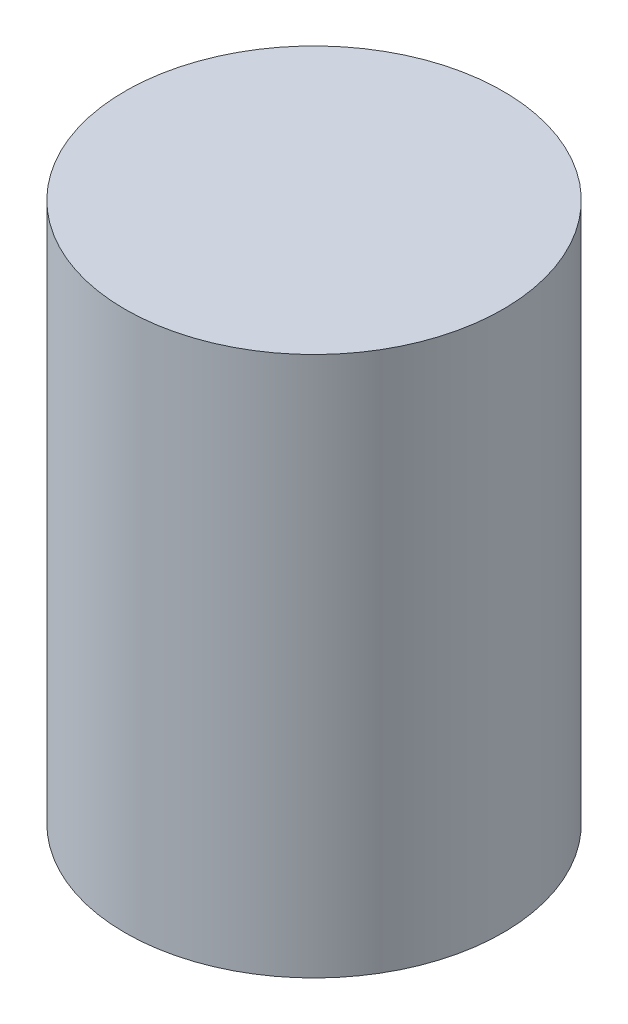
from build123d import *

# Parameters (mm, degrees)
SKETCH1_R           = 0.7
BOSS_EXTRUDE1_DEPTH = 2


with BuildPart() as part:
    # Sketch1 → Boss-Extrude1 (new body)
    with BuildSketch(Plane(origin=(0, 0, 0), x_dir=(1, 0, 0), z_dir=(0, 1, 0))):
        Circle(SKETCH1_R)
    extrude(amount=BOSS_EXTRUDE1_DEPTH)


solid = part.part
